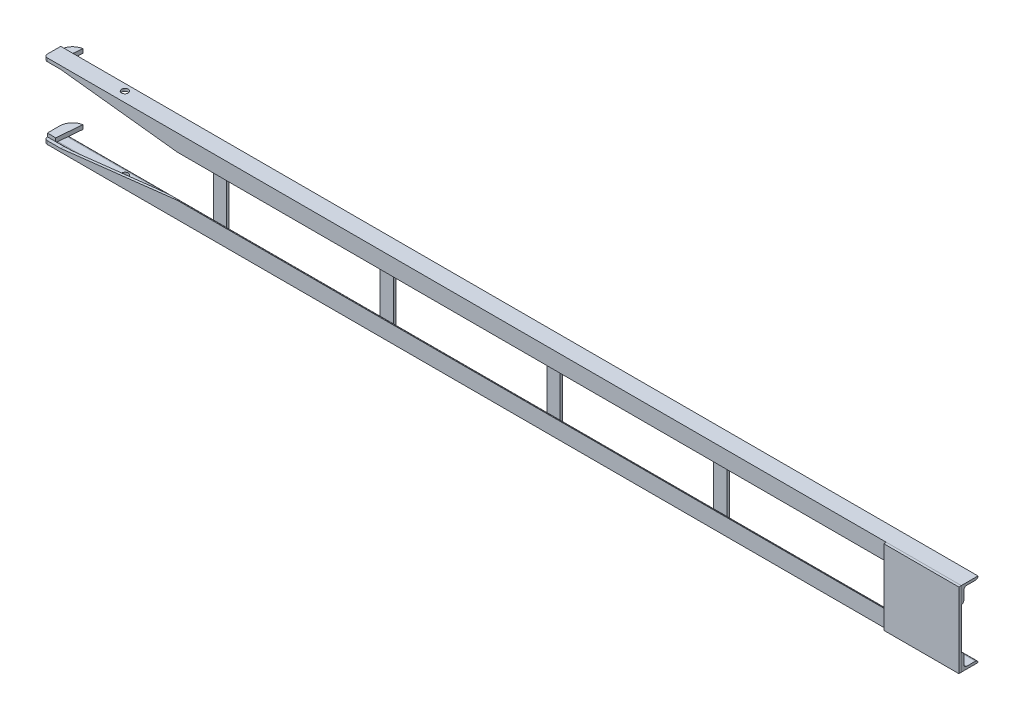
from build123d import *

# Parameters (mm, degrees)
L_ANGLE_EQUAL_20X20X3_6_DEPTH = 1100
L_ANGLE_EQUAL_20X20X3_7_DEPTH = 1100
SKETCH16_R                    = 4
CUT_EXTRUDE1_DEPTH            = 1104.85687478
SKETCH18_W                    = 90
SKETCH18_H                    = 90
BOSS_EXTRUDE1_DEPTH           = 3
CUT_EXTRUDE2_DEPTH            = 4
BOSS_EXTRUDE2_DEPTH           = 5
BOSS_EXTRUDE3_DEPTH           = 5
FILLET1_R                     = 4
FILLET2_R                     = 4
SKETCH23_W                    = 16
SKETCH23_H                    = 70
BOSS_EXTRUDE4_DEPTH           = 3
BOSS_EXTRUDE4_2_DEPTH         = 3
BOSS_EXTRUDE4_3_DEPTH         = 3
BOSS_EXTRUDE4_4_DEPTH         = 3


with BuildPart() as part:
    # Sketch17 → L angle (equal) 20X20X3(6) (new body)
    with BuildSketch(Plane(origin=(0, 0, 0), x_dir=(0, -1, 0), z_dir=(1, 0, 0))):
        with BuildLine():
            Line((0, 20), (0, 0))
            Line((0, 0), (20, 0))
            ThreePointArc((20, 0), (19.121320344, 2.121320344), (17, 3))
            Line((17, 3), (6.5, 3))
            ThreePointArc((6.5, 3), (4.025126266, 4.025126266), (3, 6.5))
            Line((3, 6.5), (3, 17))
            ThreePointArc((3, 17), (2.121320344, 19.121320344), (0, 20))
        make_face()
    extrude(amount=L_ANGLE_EQUAL_20X20X3_6_DEPTH)


with BuildPart() as body_2:
    # Sketch19 → L angle (equal) 20X20X3(7) (new body)
    with BuildSketch(Plane(origin=(0, -90, 0), x_dir=(0, 1, 0), z_dir=(-1, 0, 0))):
        with BuildLine():
            Line((0, 20), (0, 0))
            Line((0, 0), (20, 0))
            ThreePointArc((20, 0), (19.121320344, 2.121320344), (17, 3))
            Line((17, 3), (6.5, 3))
            ThreePointArc((6.5, 3), (4.025126266, 4.025126266), (3, 6.5))
            Line((3, 6.5), (3, 17))
            ThreePointArc((3, 17), (2.121320344, 19.121320344), (0, 20))
        make_face()
    extrude(amount=-L_ANGLE_EQUAL_20X20X3_7_DEPTH)


with BuildPart() as cut_extrude1_tool:
    # Sketch16 → Cut-Extrude1 (new, through all)
    with BuildSketch(Plane.XZ.offset(90)):
        with Locations(Location((85, -12, 0), (0, 0, 270))):
            Circle(SKETCH16_R)
    extrude(amount=-CUT_EXTRUDE1_DEPTH)


with BuildPart() as part_1:
    add(part.part)

    # Cut-Extrude1: cut by cut_extrude1_tool
    add(cut_extrude1_tool.part, mode=Mode.SUBTRACT)


with BuildPart() as body_2_1:
    add(body_2.part)

    # Cut-Extrude1: cut by cut_extrude1_tool
    add(cut_extrude1_tool.part, mode=Mode.SUBTRACT)


with BuildPart() as body_3:
    # Sketch18 → Boss-Extrude1 (new body)
    with BuildSketch(Plane.XY):
        with Locations((1055, -45)):
            Rectangle(SKETCH18_W, SKETCH18_H)
    extrude(amount=BOSS_EXTRUDE1_DEPTH)


with BuildPart() as cut_extrude2_tool:
    # Sketch20 → Cut-Extrude2 (new body)
    with BuildSketch(Plane.XY):
        Polygon((0, -86), (20, -86), (160, -70), (0, -70), align=None)
        Polygon((0, -20), (160, -20), (20, -4), (0, -4), align=None)
    extrude(amount=-CUT_EXTRUDE2_DEPTH)


with BuildPart() as part_2:
    add(part_1.part)

    # Cut-Extrude2: cut by cut_extrude2_tool
    add(cut_extrude2_tool.part, mode=Mode.SUBTRACT)

    # Fillet2
    fillet2_edges = [part_2.edges().sort_by_distance(p)[0] for p in [
        (0, -2, 0),
    ]]
    fillet(fillet2_edges, radius=FILLET2_R)


with BuildPart() as body_2_2:
    add(body_2_1.part)

    # Cut-Extrude2: cut by cut_extrude2_tool
    add(cut_extrude2_tool.part, mode=Mode.SUBTRACT)

    # Fillet1
    fillet1_edges = [body_2_2.edges().sort_by_distance(p)[0] for p in [
        (0, -88, 0),
    ]]
    fillet(fillet1_edges, radius=FILLET1_R)


with BuildPart() as body_4:
    # Sketch21 → Boss-Extrude2 (new body)
    with BuildSketch(Plane.XZ.offset(3)):
        with BuildLine():
            Line((0, -4), (10, -4))
            Line((10, -4), (12.62465991, -34))
            add(Edge.make_bspline(
                [(12.62465991, -34), (1.75888124, -31.534337235), (0, -20)],
                knots=[0, 0, 0, 1, 1, 1], degree=2))
            Line((0, -20), (0, -4))
        make_face()
    extrude(amount=BOSS_EXTRUDE2_DEPTH)


with BuildPart() as body_5:
    # Sketch22 → Boss-Extrude3 (new body)
    with BuildSketch(Plane(origin=(0, -87, 0), x_dir=(1, 0, 0), z_dir=(0, 1, 0))):
        with BuildLine():
            Line((0, 20), (0, 4))
            Line((0, 4), (10, 4))
            Line((10, 4), (12.62465991, 34))
            add(Edge.make_bspline(
                [(12.62465991, 34), (1.75888124, 31.534337235), (0, 20)],
                knots=[0, 0, 0, 1, 1, 1], degree=2))
        make_face()
    extrude(amount=BOSS_EXTRUDE3_DEPTH)


with BuildPart() as body_6:
    # Sketch23 → Boss-Extrude4 (new body)
    with BuildSketch(Plane(origin=(0, 0, -3), x_dir=(-1, 0, 0), z_dir=(0, 0, -1))):
        with Locations((-408, -45)):
            Rectangle(SKETCH23_W, SKETCH23_H)
    extrude(amount=BOSS_EXTRUDE4_DEPTH)


with BuildPart() as body_7:
    # Sketch23 → Boss-Extrude4 2 (new body)
    with BuildSketch(Plane(origin=(0, 0, -3), x_dir=(-1, 0, 0), z_dir=(0, 0, -1))):
        with Locations((-608, -45)):
            Rectangle(SKETCH23_W, SKETCH23_H)
    extrude(amount=BOSS_EXTRUDE4_2_DEPTH)


with BuildPart() as body_8:
    # Sketch23 → Boss-Extrude4 3 (new body)
    with BuildSketch(Plane(origin=(0, 0, -3), x_dir=(-1, 0, 0), z_dir=(0, 0, -1))):
        with Locations((-208, -45)):
            Rectangle(SKETCH23_W, SKETCH23_H)
    extrude(amount=BOSS_EXTRUDE4_3_DEPTH)


with BuildPart() as body_9:
    # Sketch23 → Boss-Extrude4 4 (new body)
    with BuildSketch(Plane(origin=(0, 0, -3), x_dir=(-1, 0, 0), z_dir=(0, 0, -1))):
        with Locations((-808, -45)):
            Rectangle(SKETCH23_W, SKETCH23_H)
    extrude(amount=BOSS_EXTRUDE4_4_DEPTH)


solid = Compound([body_3.part, part_2.part, body_2_2.part, body_4.part, body_5.part, body_6.part, body_7.part, body_8.part, body_9.part])
